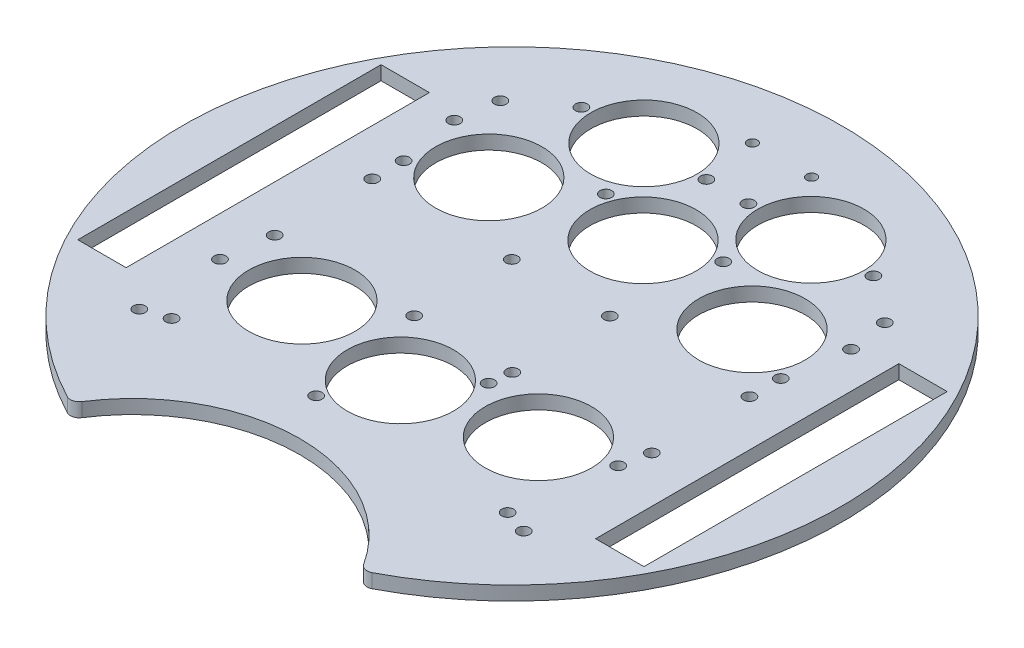
from build123d import *

# Parameters (mm, degrees)
SKETCH1_R           = 1.35
SKETCH1_R_2         = 12.095
SKETCH1_R_3         = 1.143
SKETCH1_W           = 11
SKETCH1_H           = 69
BOSS_EXTRUDE2_DEPTH = 3.175
FILLET1_R           = 2


with BuildPart() as part:
    # Sketch1 → Boss-Extrude2 (new body)
    with BuildSketch(Plane(origin=(0, 0, 0), x_dir=(1, 0, 0), z_dir=(0, 1, 0))):
        with BuildLine():
            ThreePointArc((32.995567884, -67.352004425), (0, 75), (-32.995567884, -67.352004425))
            ThreePointArc((-32.995567884, -67.352004425), (0, -48.302004425), (32.995567884, -67.352004425))
        make_face()
        with Locations((-42.910067426, 11.1)):
            Circle(SKETCH1_R, mode=Mode.SUBTRACT)
        with Locations((-42.910067426, -11.1)):
            Circle(SKETCH1_R, mode=Mode.SUBTRACT)
        with Locations((-11.160067426, -11.1)):
            Circle(SKETCH1_R, mode=Mode.SUBTRACT)
        with Locations((-11.160067426, 11.1)):
            Circle(SKETCH1_R, mode=Mode.SUBTRACT)
        with Locations((11.160067426, 11.1)):
            Circle(SKETCH1_R, mode=Mode.SUBTRACT)
        with Locations((11.160067426, -11.1)):
            Circle(SKETCH1_R, mode=Mode.SUBTRACT)
        with Locations((42.910067426, -11.1)):
            Circle(SKETCH1_R, mode=Mode.SUBTRACT)
        with Locations((42.910067426, 11.1)):
            Circle(SKETCH1_R, mode=Mode.SUBTRACT)
        with Locations((26.905821676, -20.904643604)):
            Circle(SKETCH1_R_2, mode=Mode.SUBTRACT)
        with Locations((19, 49)):
            Circle(SKETCH1_R_2, mode=Mode.SUBTRACT)
        with Locations((0, 29.793589551)):
            Circle(SKETCH1_R_2, mode=Mode.SUBTRACT)
        with Locations((0, -25.409190322)):
            Circle(SKETCH1_R_2, mode=Mode.SUBTRACT)
        with Locations((29.939937248, 24.651901309)):
            Circle(SKETCH1_R_2, mode=Mode.SUBTRACT)
        with Locations((-26.905821676, -20.904643604)):
            Circle(SKETCH1_R_2, mode=Mode.SUBTRACT)
        with Locations((6.731, 61.422565207)):
            Circle(SKETCH1_R_3, mode=Mode.SUBTRACT)
        with Locations((-6.731, 61.422565207)):
            Circle(SKETCH1_R_3, mode=Mode.SUBTRACT)
        with Locations((-29.939937248, 24.651901309)):
            Circle(SKETCH1_R_2, mode=Mode.SUBTRACT)
        with Locations((-33.21799214, 49)):
            Circle(SKETCH1_R, mode=Mode.SUBTRACT)
        with Locations((-4.78200786, 49)):
            Circle(SKETCH1_R, mode=Mode.SUBTRACT)
        with Locations((4.78200786, 49)):
            Circle(SKETCH1_R, mode=Mode.SUBTRACT)
        with Locations((-42.910067426, 18.234848025)):
            Circle(SKETCH1_R, mode=Mode.SUBTRACT)
        with Locations((42.910067426, 18.234848025)):
            Circle(SKETCH1_R, mode=Mode.SUBTRACT)
        with Locations((-19, 49)):
            Circle(SKETCH1_R_2, mode=Mode.SUBTRACT)
        with Locations((45.13872464, 31.997163897)):
            Circle(SKETCH1_R, mode=Mode.SUBTRACT)
        with Locations((-45.13872464, 31.997163897)):
            Circle(SKETCH1_R, mode=Mode.SUBTRACT)
        with Locations((13.346873881, 34.693819966)):
            Circle(SKETCH1_R, mode=Mode.SUBTRACT)
        with Locations((-6.55476095, -38.026099982)):
            Circle(SKETCH1_R, mode=Mode.SUBTRACT)
        with Locations((-13.346873881, 34.693819966)):
            Circle(SKETCH1_R, mode=Mode.SUBTRACT)
        with Locations((10.597026674, -15.930038136)):
            Circle(SKETCH1_R, mode=Mode.SUBTRACT)
        with Locations((-38.234289702, -39.23697625)):
            Circle(SKETCH1_R, mode=Mode.SUBTRACT)
        with Locations((-43.735655662, -41.075447944)):
            Circle(SKETCH1_R, mode=Mode.SUBTRACT)
        with Locations((-43.735655662, 41.075447944)):
            Circle(SKETCH1_R, mode=Mode.SUBTRACT)
        with Locations((43.735655662, -41.075447944)):
            Circle(SKETCH1_R, mode=Mode.SUBTRACT)
        with Locations((33.21799214, 49)):
            Circle(SKETCH1_R, mode=Mode.SUBTRACT)
        with Locations((43.735655662, 41.075447944)):
            Circle(SKETCH1_R, mode=Mode.SUBTRACT)
        with Locations((-44.385223141, -22.074211772)):
            Circle(SKETCH1_R, mode=Mode.SUBTRACT)
        with Locations((41.601681906, -17.457756634)):
            Circle(SKETCH1_R, mode=Mode.SUBTRACT)
        with Locations((38.234289702, -39.23697625)):
            Circle(SKETCH1_R, mode=Mode.SUBTRACT)
        with Locations((58.910067426, 0.102907352)):
            Rectangle(SKETCH1_W, SKETCH1_H, mode=Mode.SUBTRACT)
        with Locations((-58.910067426, 0.102907352)):
            Rectangle(SKETCH1_W, SKETCH1_H, mode=Mode.SUBTRACT)
    extrude(amount=BOSS_EXTRUDE2_DEPTH)

    # Fillet1
    fillet1_edges = [part.edges().sort_by_distance(p)[0] for p in [
        (-32.995567884, 1.5875, 67.352004425),
        (32.995567884, 1.5875, 67.352004425),
    ]]
    fillet(fillet1_edges, radius=FILLET1_R)


solid = part.part
